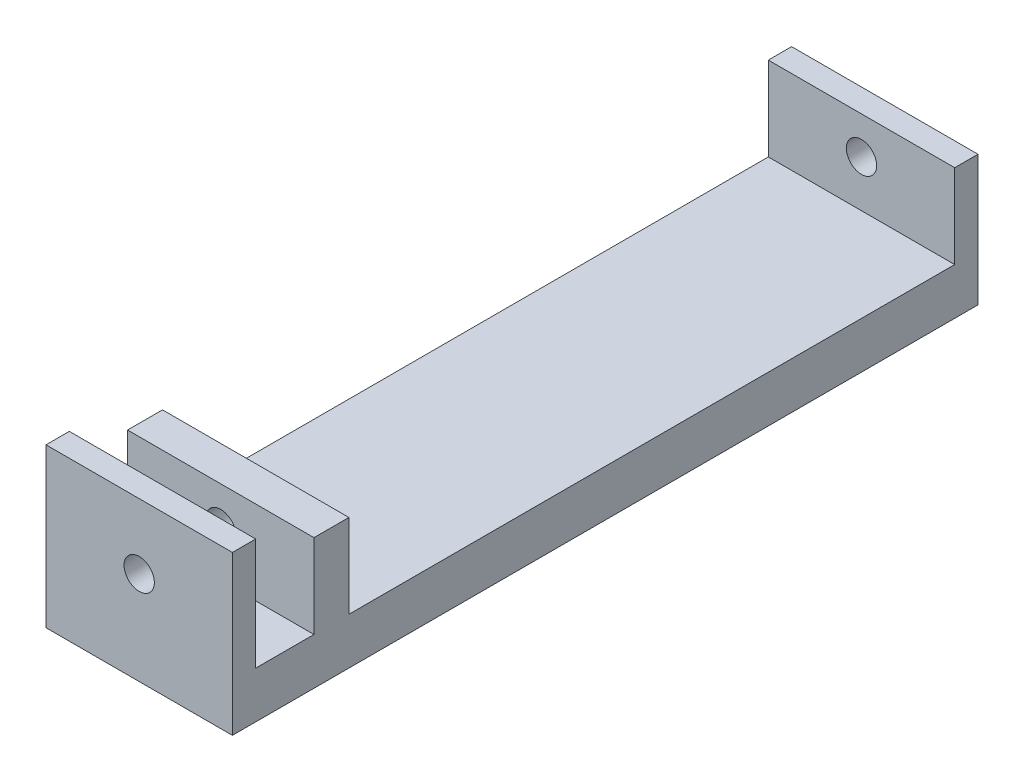
from build123d import *

# Parameters (mm, degrees)
SKETCH1_W           = 15
SKETCH1_H           = 36
BOSS_EXTRUDE1_DEPTH = 80
SKETCH2_R           = 6.5
CUT_EXTRUDE1_DEPTH  = 321


with BuildPart() as part:
    # Sketch1 → Boss-Extrude1 (new body)
    with BuildSketch(Plane(origin=(0, 0, 0), x_dir=(0, 0, -1), z_dir=(1, 0, 0))):
        with Locations((42.5, 38)):
            Rectangle(SKETCH1_W, SKETCH1_H)
        Polygon((320, 56), (310, 56), (310, 20), (10, 20), (10, 68), (0, 68), (0, 20), (0, 0), (320, 0), (320, 20), align=None)
    extrude(amount=BOSS_EXTRUDE1_DEPTH)

    # Sketch2 → Cut-Extrude1 (cut, through all)
    with BuildSketch(Plane(origin=(0, 0, -320), x_dir=(-1, 0, 0), z_dir=(0, 0, -1))):
        with Locations((-40, 40)):
            Circle(SKETCH2_R)
    extrude(amount=-CUT_EXTRUDE1_DEPTH, mode=Mode.SUBTRACT)


solid = part.part
